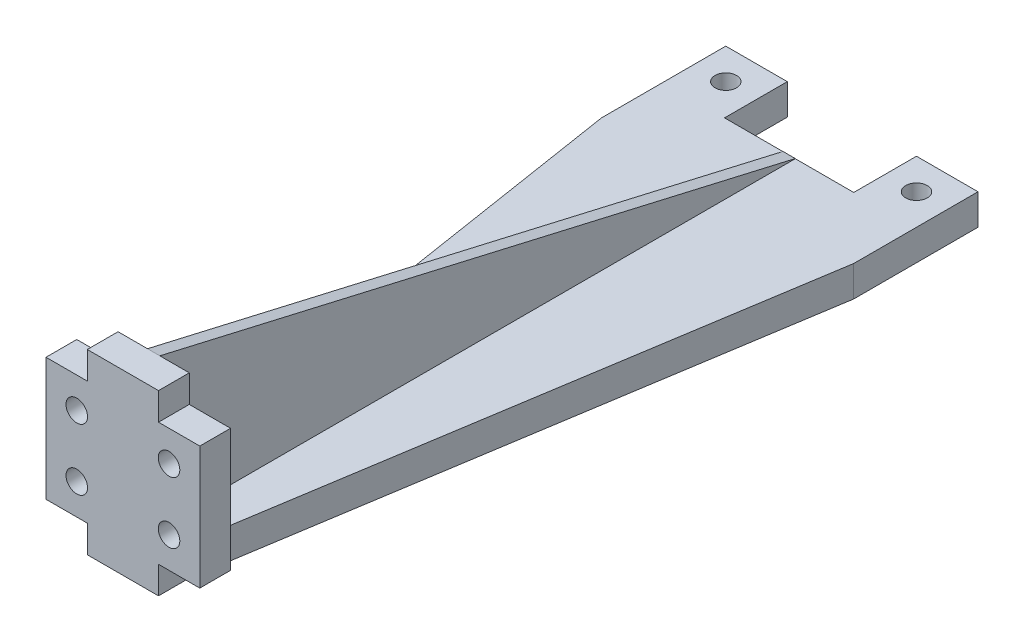
from build123d import *

# Parameters (mm, degrees)
SKETCH1_W           = 41
SKETCH1_H           = 118.5
BOSS_EXTRUDE1_DEPTH = 5
SKETCH2_W           = 21
SKETCH2_H           = 10.2
CUT_EXTRUDE1_DEPTH  = 6
SKETCH9_R           = 1.75
CUT_EXTRUDE4_DEPTH  = 6
CUT_EXTRUDE5_DEPTH  = 6
BOSS_EXTRUDE4_DEPTH = 23.9
SKETCH16_W          = 2
SKETCH16_H          = 103.3
BOSS_EXTRUDE5_DEPTH = 23.9
CUT_EXTRUDE8_DEPTH  = 22.5
BOSS_EXTRUDE6_DEPTH = 28.9
SKETCH25_W          = 6.711597152
SKETCH25_H          = 4.45
CUT_EXTRUDE9_DEPTH  = 6
SKETCH26_R          = 1.75
CUT_EXTRUDE10_DEPTH = 119.5


with BuildPart() as part:
    # Sketch1 → Boss-Extrude1 (new body)
    with BuildSketch(Plane(origin=(0, 0, 0), x_dir=(1, 0, 0), z_dir=(0, 1, 0))):
        with Locations((20.5, 59.25)):
            Rectangle(SKETCH1_W, SKETCH1_H)
    extrude(amount=BOSS_EXTRUDE1_DEPTH)

    # Sketch2 → Cut-Extrude1 (cut, through all)
    with BuildSketch(Plane(origin=(0, 5, 0), x_dir=(1, 0, 0), z_dir=(0, 1, 0))):
        with Locations((20.5, 113.4)):
            Rectangle(SKETCH2_W, SKETCH2_H)
    extrude(amount=-CUT_EXTRUDE1_DEPTH, mode=Mode.SUBTRACT)

    # Sketch9 → Cut-Extrude4 (cut, through all)
    with BuildSketch(Plane(origin=(0, 5, 0), x_dir=(1, 0, 0), z_dir=(0, 1, 0))):
        with Locations((5, 113.5)):
            Circle(SKETCH9_R)
        with Locations((36, 113.5)):
            Circle(SKETCH9_R)
    extrude(amount=-CUT_EXTRUDE4_DEPTH, mode=Mode.SUBTRACT)

    # Sketch11 → Cut-Extrude5 (cut, through all)
    with BuildSketch(Plane(origin=(0, 5, 0), x_dir=(1, 0, 0), z_dir=(0, 1, 0))):
        Polygon((15.5, 0), (0, 98.3), (0, 0), align=None)
        Polygon((25.5, 0), (41, 98.3), (41, 0), align=None)
    extrude(amount=-CUT_EXTRUDE5_DEPTH, mode=Mode.SUBTRACT)

    # Sketch12 → Boss-Extrude4 (add)
    with BuildSketch(Plane(origin=(0, 5, 0), x_dir=(1, 0, 0), z_dir=(0, 1, 0))):
        Polygon((25.5, 0), (15.5, 0), (14.711597152, 5), (26.288402848, 5), align=None)
    extrude(amount=BOSS_EXTRUDE4_DEPTH)

    # Sketch16 → Boss-Extrude5 (add)
    with BuildSketch(Plane(origin=(0, 5, 0), x_dir=(1, 0, 0), z_dir=(0, 1, 0))):
        with Locations((20.5, 56.65)):
            Rectangle(SKETCH16_W, SKETCH16_H)
    extrude(amount=BOSS_EXTRUDE5_DEPTH)

    # Sketch17 → Cut-Extrude8 (cut, through all)
    with BuildSketch(Plane.ZY.offset(-19.5)):
        Polygon((-108.4, 5), (-5, 28.9), (-108.3, 28.9), align=None)
    extrude(amount=-CUT_EXTRUDE8_DEPTH, mode=Mode.SUBTRACT)

    # Sketch23 → Boss-Extrude6 (add)
    with BuildSketch(Plane(origin=(0, 28.9, 0), x_dir=(1, 0, 0), z_dir=(0, 1, 0))):
        Polygon((26.288402848, 5), (33, 5), (33, 0), (25.5, 0), align=None)
        Polygon((14.711597152, 5), (8, 5), (8, 0), (15.5, 0), align=None)
    extrude(amount=-BOSS_EXTRUDE6_DEPTH)

    # Sketch25 → Cut-Extrude9 (cut, through all)
    with BuildSketch(Plane(origin=(0, 0, -5), x_dir=(-1, 0, 0), z_dir=(0, 0, -1))):
        with Locations((-11.355798576, 2.225)):
            Rectangle(SKETCH25_W, SKETCH25_H)
        with Locations((-29.644201424, 2.225)):
            Rectangle(SKETCH25_W, SKETCH25_H)
        with Locations((-11.355798576, 26.675)):
            Rectangle(SKETCH25_W, SKETCH25_H)
        with Locations((-29.644201424, 26.675)):
            Rectangle(SKETCH25_W, SKETCH25_H)
    extrude(amount=-CUT_EXTRUDE9_DEPTH, mode=Mode.SUBTRACT)

    # Sketch26 → Cut-Extrude10 (cut, through all)
    with BuildSketch(Plane.XY):
        with Locations((13, 19.45)):
            Circle(SKETCH26_R)
        with Locations((28, 19.45)):
            Circle(SKETCH26_R)
        with Locations((13, 9.45)):
            Circle(SKETCH26_R)
        with Locations((28, 9.45)):
            Circle(SKETCH26_R)
    extrude(amount=-CUT_EXTRUDE10_DEPTH, mode=Mode.SUBTRACT)


solid = part.part
